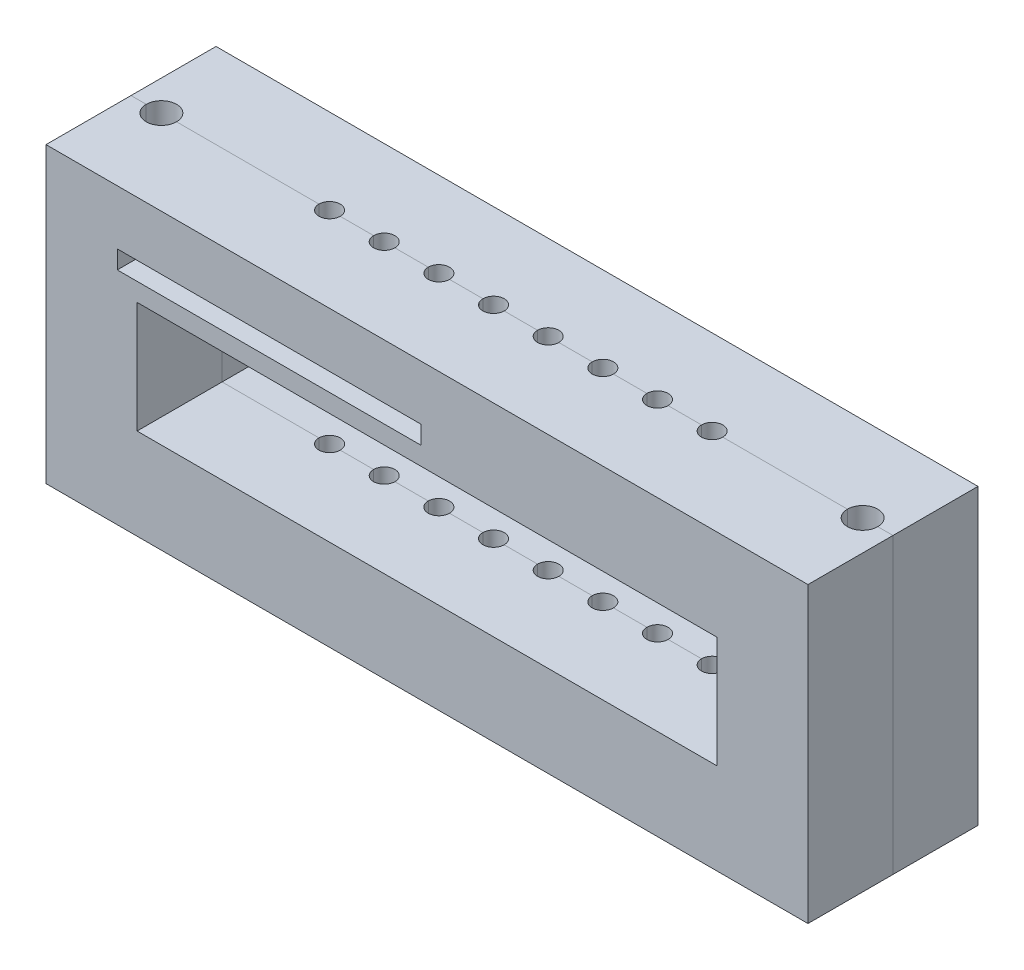
from build123d import *

# Parameters (mm, degrees)
BASE_SKETCH_W                                = 125.48
BASE_SKETCH_H                                = 48.35
BASE_SKETCH_W_2                              = 95.48
BASE_SKETCH_H_2                              = 18.35
BASE_EXTRUSION_DEPTH                         = 14
LED_START                                    = -3
LED_HOLE_SKETCH_R                            = 3.5
LED_HOLE_DEPTH                               = 12
LENS_HOLE_SKETCH_R                           = 1.75
LENS_HOLE_DEPTH                              = 3
BOTTOM_LINEAR_PATTERN_COUNT                  = 8
BOTTOM_LINEAR_PATTERN_PITCH                  = 9
FILTER_SLOT_SKETCH_W                         = 50
FILTER_SLOT_SKETCH_H                         = 3
FILTER_SLOT_CUT_DEPTH                        = 20
SKETCH6_R                                    = 1.75
PHOTODIODE_HOLE_DEPTH                        = 15
SKETCH9_R                                    = 3.5
SKETCH9_R_2                                  = 1.75
LIGHT_SHADE_DEPTH                            = 5
PHOTODIODE_LINEAR_PATTERN_COUNT              = 8
PHOTODIODE_LINEAR_PATTERN_PITCH              = 9
PHOTODIODE_AND_FILTER_CIRCULAR_PATTERN_COUNT = 2
BOLT_HOLE_SKETCH_R                           = 2.5
BOLT_HOLE_DEPTH                              = 48.35


with BuildPart() as part:
    # Base sketch → Base extrusion (new body, symmetric)
    with BuildSketch(Plane.XY):
        Rectangle(BASE_SKETCH_W, BASE_SKETCH_H)
        Rectangle(BASE_SKETCH_W_2, BASE_SKETCH_H_2, mode=Mode.SUBTRACT)
    extrude(amount=BASE_EXTRUSION_DEPTH, both=True)

    # LED hole sketch → LED hole (cut)
    with BuildSketch(Plane(origin=(0, -9.175, 0), x_dir=(1, 0, 0), z_dir=(0, 1, 0)).offset(LED_START)):
        with Locations((-30.04, 0)):
            Circle(LED_HOLE_SKETCH_R)
    led_hole = extrude(amount=-LED_HOLE_DEPTH, mode=Mode.SUBTRACT)

    # lens hole sketch → lens hole (cut)
    with BuildSketch(Plane.XZ.offset(12.175)):
        with Locations((-30.04, 0)):
            Circle(LENS_HOLE_SKETCH_R)
    lens_hole = extrude(amount=-LENS_HOLE_DEPTH, mode=Mode.SUBTRACT)

    # bottom linear pattern: LED hole, lens hole ×8
    with Locations(*[(i * BOTTOM_LINEAR_PATTERN_PITCH, 0, 0) for i in range(1, BOTTOM_LINEAR_PATTERN_COUNT)]):
        add(led_hole, mode=Mode.SUBTRACT)
        add(lens_hole, mode=Mode.SUBTRACT)

    # filter slot sketch → filter slot cut (cut)
    with BuildSketch(Plane.XY.offset(14)):
        with Locations((-26, 13.675)):
            Rectangle(FILTER_SLOT_SKETCH_W, FILTER_SLOT_SKETCH_H)
    filter_slot_cut = extrude(amount=-FILTER_SLOT_CUT_DEPTH, mode=Mode.SUBTRACT)

    # Sketch6 → photodiode hole (cut)
    with BuildSketch(Plane.XZ.offset(-9.175)):
        with Locations((-30.04, 0)):
            Circle(SKETCH6_R)
    photodiode_hole = extrude(amount=-PHOTODIODE_HOLE_DEPTH, mode=Mode.SUBTRACT)

    # Sketch9 → Light shade (add)
    with BuildSketch(Plane.XZ.offset(-9.175)):
        with Locations((-30.04, 0)):
            Circle(SKETCH9_R)
        with Locations((-30.04, 0)):
            Circle(SKETCH9_R_2, mode=Mode.SUBTRACT)
    light_shade = extrude(amount=LIGHT_SHADE_DEPTH)

    # photodiode linear pattern: photodiode hole, Light shade ×8
    with Locations(*[(i * PHOTODIODE_LINEAR_PATTERN_PITCH, 0, 0) for i in range(1, PHOTODIODE_LINEAR_PATTERN_COUNT)]):
        add(photodiode_hole, mode=Mode.SUBTRACT)
        add(light_shade)

    # photodiode and filter circular pattern: filter slot cut ×2 about axis
    photodiode_and_filter_circular_pattern_axis = Axis((0, 0, 0), (0, 1, 0))
    for i in range(1, PHOTODIODE_AND_FILTER_CIRCULAR_PATTERN_COUNT):
        add(filter_slot_cut.rotate(photodiode_and_filter_circular_pattern_axis, i * 360 / PHOTODIODE_AND_FILTER_CIRCULAR_PATTERN_COUNT), mode=Mode.SUBTRACT)

    # bolt hole sketch → Bolt hole (cut)
    with BuildSketch(Plane(origin=(0, 24.175, 0), x_dir=(1, 0, 0), z_dir=(0, 1, 0))):
        with Locations((-57.74, 0)):
            Circle(BOLT_HOLE_SKETCH_R)
        with Locations((57.74, 0)):
            Circle(BOLT_HOLE_SKETCH_R)
    extrude(amount=-BOLT_HOLE_DEPTH, mode=Mode.SUBTRACT)


with BuildPart() as body_2:
    # Split1: the piece on the far side of the plane
    add(part.part)
    split(bisect_by=Plane.XY, keep=Keep.BOTTOM)


with BuildPart() as part_1:
    add(part.part)

    # Split1
    split(bisect_by=Plane.XY, keep=Keep.TOP)


solid = Compound([body_2.part, part_1.part])
